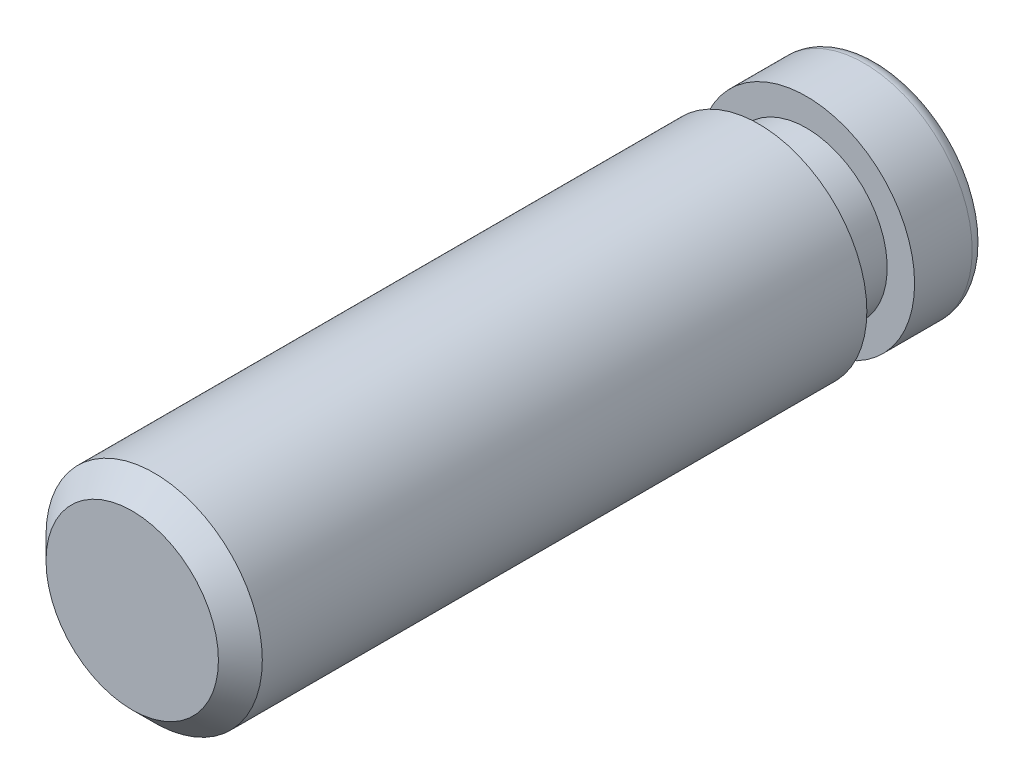
from build123d import *

# Parameters (mm, degrees)
SKETCH1_R      = 1.9558
EXTRUDE1_DEPTH = 6.7437
SKETCH2_W      = 0.4953
SKETCH2_H      = 0.8636
FILLET1_R      = 0.254
CHAMFER1_SIZE  = 0.396875


with BuildPart() as part:
    # Sketch1 → Extrude1 (new body, symmetric)
    with BuildSketch(Plane.XY):
        Circle(SKETCH1_R)
    extrude(amount=EXTRUDE1_DEPTH, both=True)

    # Sketch2 → Cut-Revolve1 (revolve, cut)
    with BuildSketch(Plane(origin=(0, 0, 0), x_dir=(1, 0, 0), z_dir=(0, 1, 0))):
        with Locations((1.70815, 5.0165)):
            Rectangle(SKETCH2_W, SKETCH2_H)
    revolve(axis=Axis((0, 0, -10.042474892), (0, 0, 1)), mode=Mode.SUBTRACT)

    # Fillet1
    fillet1_edges = [part.edges().sort_by_distance(p)[0] for p in [
        (-1.9558, 0, -6.7437),
    ]]
    fillet(fillet1_edges, radius=FILLET1_R)

    # Chamfer1
    chamfer1_edges = [part.edges().sort_by_distance(p)[0] for p in [
        (-1.9558, 0, 6.7437),
    ]]
    chamfer(chamfer1_edges, length=CHAMFER1_SIZE)


solid = part.part
